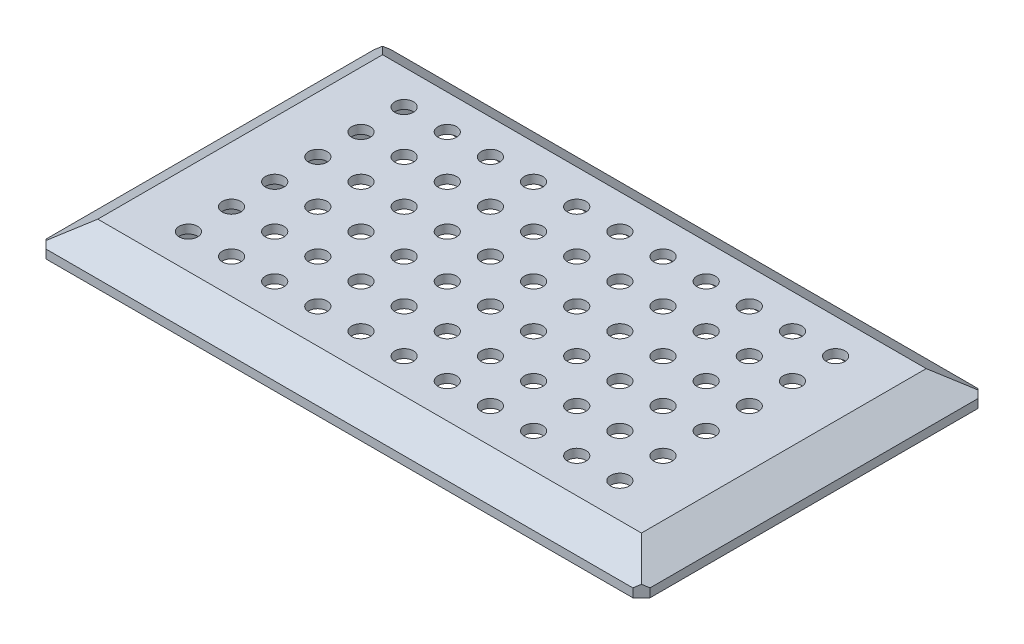
from build123d import *

# Parameters (mm, degrees)
SKETCH1_W                       = 140
SKETCH1_H                       = 80
BOSS_EXTRUDE1_DEPTH             = 2
SKETCH3_W                       = 126
SKETCH3_H                       = 66
SKETCH2_W                       = 140
SKETCH2_H                       = 80
CHAMFER2_SIZE                   = 2
SKETCH4_W                       = 8
SKETCH4_H                       = 10
BOSS_EXTRUDE2_DEPTH             = 7
SKETCH5_R                       = 2.05
CUT_EXTRUDE1_DEPTH              = 133.9000001
SKETCH6_W                       = 107.8
SKETCH6_H                       = 64
CUT_EXTRUDE2_DEPTH              = 5
SKIZZE1_R                       = 2.15
SCHNITT_LINEAR_AUSTRAGEN2_DEPTH = 10


with BuildPart() as part:
    # Sketch1 → Boss-Extrude1 (new body)
    with BuildSketch(Plane(origin=(0, 0, 0), x_dir=(1, 0, 0), z_dir=(0, 1, 0))):
        Rectangle(SKETCH1_W, SKETCH1_H)
    extrude(amount=BOSS_EXTRUDE1_DEPTH)

    # Sketch3 → Loft1 section 0
    with BuildSketch(Plane(origin=(0, 7, 0), x_dir=(1, 0, 0), z_dir=(0, 1, 0))):
        Rectangle(SKETCH3_W, SKETCH3_H)
    # Sketch2 → Loft1 section 1
    with BuildSketch(Plane(origin=(0, 2, 0), x_dir=(1, 0, 0), z_dir=(0, 1, 0))):
        Rectangle(SKETCH2_W, SKETCH2_H)
    loft()

    # Chamfer2
    chamfer2_edges = [part.edges().sort_by_distance(p)[0] for p in [
        (70, 1, 40),
        (-70, 1, 40),
        (-70, 1, -40),
        (70, 1, -40),
    ]]
    chamfer(chamfer2_edges, length=CHAMFER2_SIZE)

    # Sketch4 → Boss-Extrude2 (add)
    with BuildSketch(Plane.XZ):
        with Locations((-58.9, 20)):
            Rectangle(SKETCH4_W, SKETCH4_H)
        with Locations((-58.9, -20)):
            Rectangle(SKETCH4_W, SKETCH4_H)
        with Locations((58.9, -20)):
            Rectangle(SKETCH4_W, SKETCH4_H)
        with Locations((58.9, 20)):
            Rectangle(SKETCH4_W, SKETCH4_H)
    extrude(amount=BOSS_EXTRUDE2_DEPTH)

    # Sketch5 → Cut-Extrude1 (cut, through all)
    with BuildSketch(Plane.ZY.offset(62.9)):
        with Locations((-20, -3.5)):
            Circle(SKETCH5_R)
        with Locations((20, -3.5)):
            Circle(SKETCH5_R)
    extrude(amount=-CUT_EXTRUDE1_DEPTH, mode=Mode.SUBTRACT)

    # Sketch6 → Cut-Extrude2 (cut)
    with BuildSketch(Plane.XZ):
        Rectangle(SKETCH6_W, SKETCH6_H)
    extrude(amount=-CUT_EXTRUDE2_DEPTH, mode=Mode.SUBTRACT)

    # Skizze1 → Schnitt-Linear austragen2 (cut)
    with BuildSketch(Plane(origin=(0, 7, 0), x_dir=(1, 0, 0), z_dir=(0, 1, 0))):
        with Locations((-50, -25)):
            Circle(SKIZZE1_R)
        with Locations((-40, -25)):
            Circle(SKIZZE1_R)
        with Locations((-30, -25)):
            Circle(SKIZZE1_R)
        with Locations((-20, -25)):
            Circle(SKIZZE1_R)
        with Locations((-10, -25)):
            Circle(SKIZZE1_R)
        with Locations((0, -25)):
            Circle(SKIZZE1_R)
        with Locations((10, -25)):
            Circle(SKIZZE1_R)
        with Locations((20, -25)):
            Circle(SKIZZE1_R)
        with Locations((30, -25)):
            Circle(SKIZZE1_R)
        with Locations((40, -25)):
            Circle(SKIZZE1_R)
        with Locations((50, -25)):
            Circle(SKIZZE1_R)
        with Locations((-40, -15)):
            Circle(SKIZZE1_R)
        with Locations((-30, -15)):
            Circle(SKIZZE1_R)
        with Locations((-20, -15)):
            Circle(SKIZZE1_R)
        with Locations((-10, -15)):
            Circle(SKIZZE1_R)
        with Locations((0, -15)):
            Circle(SKIZZE1_R)
        with Locations((10, -15)):
            Circle(SKIZZE1_R)
        with Locations((20, -15)):
            Circle(SKIZZE1_R)
        with Locations((30, -15)):
            Circle(SKIZZE1_R)
        with Locations((40, -15)):
            Circle(SKIZZE1_R)
        with Locations((50, -15)):
            Circle(SKIZZE1_R)
        with Locations((-40, -5)):
            Circle(SKIZZE1_R)
        with Locations((-30, -5)):
            Circle(SKIZZE1_R)
        with Locations((-20, -5)):
            Circle(SKIZZE1_R)
        with Locations((-10, -5)):
            Circle(SKIZZE1_R)
        with Locations((0, -5)):
            Circle(SKIZZE1_R)
        with Locations((10, -5)):
            Circle(SKIZZE1_R)
        with Locations((20, -5)):
            Circle(SKIZZE1_R)
        with Locations((30, -5)):
            Circle(SKIZZE1_R)
        with Locations((40, -5)):
            Circle(SKIZZE1_R)
        with Locations((50, -5)):
            Circle(SKIZZE1_R)
        with Locations((-40, 5)):
            Circle(SKIZZE1_R)
        with Locations((-30, 5)):
            Circle(SKIZZE1_R)
        with Locations((-20, 5)):
            Circle(SKIZZE1_R)
        with Locations((-10, 5)):
            Circle(SKIZZE1_R)
        with Locations((0, 5)):
            Circle(SKIZZE1_R)
        with Locations((10, 5)):
            Circle(SKIZZE1_R)
        with Locations((20, 5)):
            Circle(SKIZZE1_R)
        with Locations((30, 5)):
            Circle(SKIZZE1_R)
        with Locations((40, 5)):
            Circle(SKIZZE1_R)
        with Locations((50, 5)):
            Circle(SKIZZE1_R)
        with Locations((-40, 15)):
            Circle(SKIZZE1_R)
        with Locations((-30, 15)):
            Circle(SKIZZE1_R)
        with Locations((-20, 15)):
            Circle(SKIZZE1_R)
        with Locations((-10, 15)):
            Circle(SKIZZE1_R)
        with Locations((0, 15)):
            Circle(SKIZZE1_R)
        with Locations((10, 15)):
            Circle(SKIZZE1_R)
        with Locations((20, 15)):
            Circle(SKIZZE1_R)
        with Locations((30, 15)):
            Circle(SKIZZE1_R)
        with Locations((40, 15)):
            Circle(SKIZZE1_R)
        with Locations((50, 15)):
            Circle(SKIZZE1_R)
        with Locations((-40, 25)):
            Circle(SKIZZE1_R)
        with Locations((-30, 25)):
            Circle(SKIZZE1_R)
        with Locations((-20, 25)):
            Circle(SKIZZE1_R)
        with Locations((-10, 25)):
            Circle(SKIZZE1_R)
        with Locations((0, 25)):
            Circle(SKIZZE1_R)
        with Locations((10, 25)):
            Circle(SKIZZE1_R)
        with Locations((20, 25)):
            Circle(SKIZZE1_R)
        with Locations((30, 25)):
            Circle(SKIZZE1_R)
        with Locations((40, 25)):
            Circle(SKIZZE1_R)
        with Locations((50, 25)):
            Circle(SKIZZE1_R)
        with Locations((-50, -15)):
            Circle(SKIZZE1_R)
        with Locations((-50, -5)):
            Circle(SKIZZE1_R)
        with Locations((-50, 5)):
            Circle(SKIZZE1_R)
        with Locations((-50, 15)):
            Circle(SKIZZE1_R)
        with Locations((-50, 25)):
            Circle(SKIZZE1_R)
    extrude(amount=-SCHNITT_LINEAR_AUSTRAGEN2_DEPTH, mode=Mode.SUBTRACT)


solid = part.part
